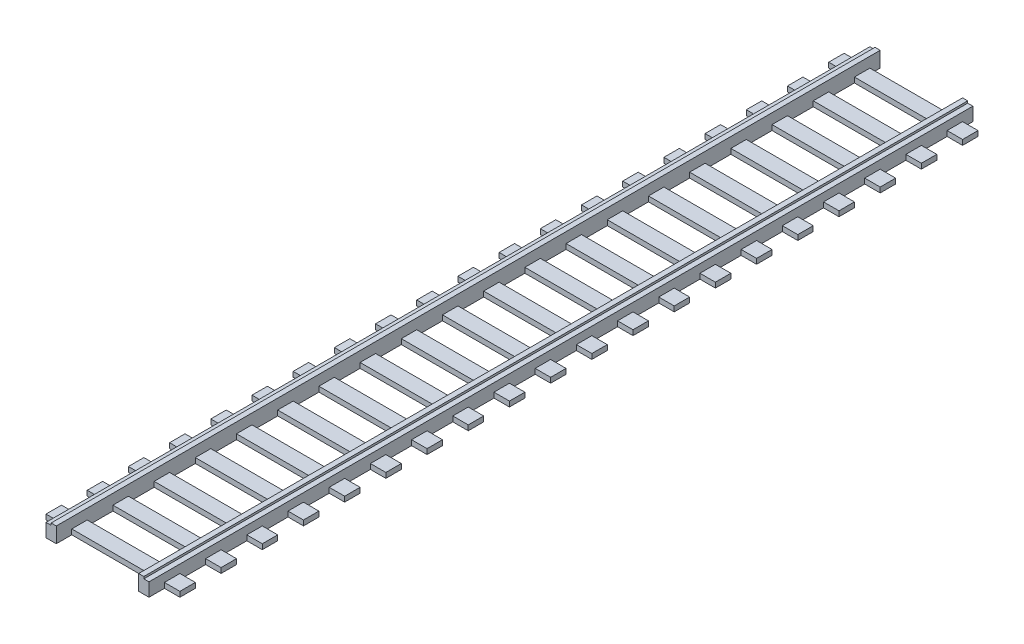
from build123d import *

# Parameters (mm, degrees)
SKETCH1_W             = 1
SKETCH1_H             = 160
BOSS_EXTRUDE1_DEPTH   = 3
BOSS_EXTRUDE1_2_DEPTH = 3
SKETCH2_W             = 1
SKETCH2_H             = 160
BOSS_EXTRUDE2_DEPTH   = 2.6
SKETCH3_W             = 26
SKETCH3_H             = 3
BOSS_EXTRUDE3_DEPTH   = 1


with BuildPart() as part:
    # Sketch1 → Boss-Extrude1 (new body)
    with BuildSketch(Plane(origin=(0, 0, 0), x_dir=(1, 0, 0), z_dir=(0, 1, 0))):
        with Locations((-43.187559699, -8.75)):
            Rectangle(SKETCH1_W, SKETCH1_H)
    extrude(amount=BOSS_EXTRUDE1_DEPTH)



with BuildPart() as body_2:
    # Sketch1 → Boss-Extrude1 2 (new body)
    with BuildSketch(Plane(origin=(0, 0, 0), x_dir=(1, 0, 0), z_dir=(0, 1, 0))):
        with Locations((-26.187559699, -8.75)):
            Rectangle(SKETCH1_W, SKETCH1_H)
    extrude(amount=BOSS_EXTRUDE1_2_DEPTH)


with BuildPart() as part_1:
    add(part.part)

    add(body_2.part)  # Boss-Extrude2 merges body 2
    # Sketch2 → Boss-Extrude2 (add)
    with BuildSketch(Plane.XZ):
        with Locations((-44.187559699, 8.75)):
            Rectangle(SKETCH2_W, SKETCH2_H)
        with Locations((-25.187559699, 8.75)):
            Rectangle(SKETCH2_W, SKETCH2_H)
    extrude(amount=-BOSS_EXTRUDE2_DEPTH)

    # Sketch3 → Boss-Extrude3 (add)
    with BuildSketch(Plane.XZ):
        with Locations((-34.687559699, 84.25)):
            Rectangle(SKETCH3_W, SKETCH3_H)
        with Locations((-34.687559699, 76.25)):
            Rectangle(SKETCH3_W, SKETCH3_H)
        with Locations((-34.687559699, 68.25)):
            Rectangle(SKETCH3_W, SKETCH3_H)
        with Locations((-34.687559699, 60.25)):
            Rectangle(SKETCH3_W, SKETCH3_H)
        with Locations((-34.687559699, 52.25)):
            Rectangle(SKETCH3_W, SKETCH3_H)
        with Locations((-34.687559699, 44.25)):
            Rectangle(SKETCH3_W, SKETCH3_H)
        with Locations((-34.687559699, 36.25)):
            Rectangle(SKETCH3_W, SKETCH3_H)
        with Locations((-34.687559699, 28.25)):
            Rectangle(SKETCH3_W, SKETCH3_H)
        with Locations((-34.687559699, 20.25)):
            Rectangle(SKETCH3_W, SKETCH3_H)
        with Locations((-34.687559699, 12.25)):
            Rectangle(SKETCH3_W, SKETCH3_H)
        with Locations((-34.687559699, 4.25)):
            Rectangle(SKETCH3_W, SKETCH3_H)
        with Locations((-34.687559699, -3.75)):
            Rectangle(SKETCH3_W, SKETCH3_H)
        with Locations((-34.687559699, -11.75)):
            Rectangle(SKETCH3_W, SKETCH3_H)
        with Locations((-34.687559699, -19.75)):
            Rectangle(SKETCH3_W, SKETCH3_H)
        with Locations((-34.687559699, -27.75)):
            Rectangle(SKETCH3_W, SKETCH3_H)
        with Locations((-34.687559699, -35.75)):
            Rectangle(SKETCH3_W, SKETCH3_H)
        with Locations((-34.687559699, -43.75)):
            Rectangle(SKETCH3_W, SKETCH3_H)
        with Locations((-34.687559699, -51.75)):
            Rectangle(SKETCH3_W, SKETCH3_H)
        with Locations((-34.687559699, -59.75)):
            Rectangle(SKETCH3_W, SKETCH3_H)
        with Locations((-34.687559699, -67.75)):
            Rectangle(SKETCH3_W, SKETCH3_H)
    extrude(amount=-BOSS_EXTRUDE3_DEPTH)


solid = part_1.part
